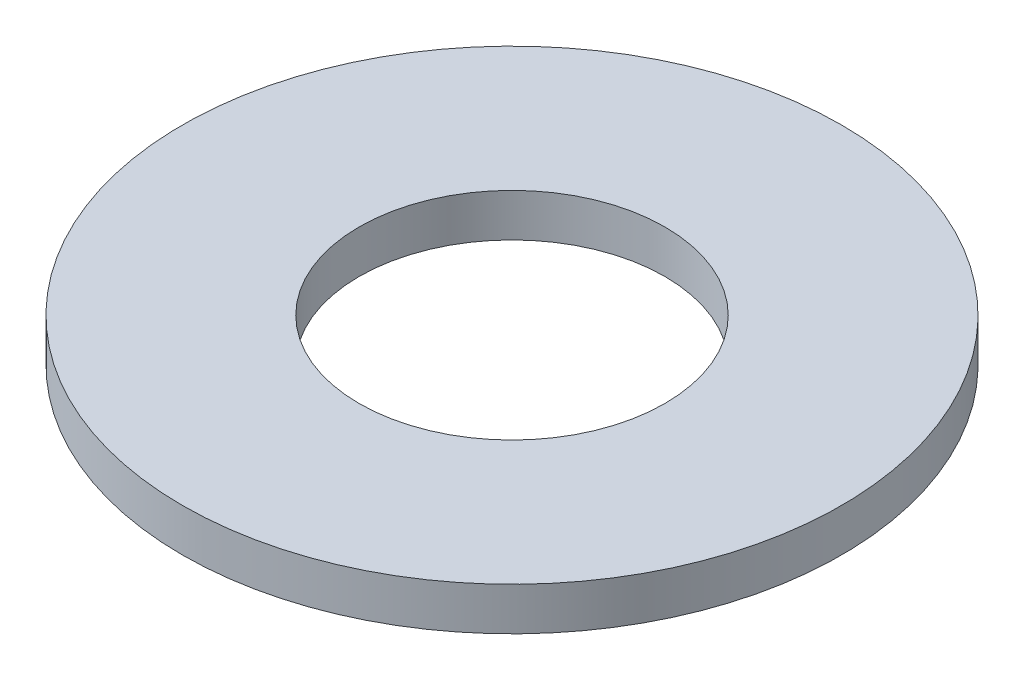
from build123d import *

# Parameters (mm, degrees)
SKETCH1_R           = 11.1125
BOSS_EXTRUDE1_DEPTH = 1.4478
SKETCH5_R           = 5.1562
CUT_EXTRUDE1_DEPTH  = 2.4478


with BuildPart() as part:
    # Sketch1 → Boss-Extrude1 (new body)
    with BuildSketch(Plane(origin=(0, 0, 0), x_dir=(1, 0, 0), z_dir=(0, 1, 0))):
        Circle(SKETCH1_R)
    extrude(amount=BOSS_EXTRUDE1_DEPTH)

    # Sketch5 → Cut-Extrude1 (cut, through all)
    with BuildSketch(Plane(origin=(0, 1.4478, 0), x_dir=(-1, 0, 0), z_dir=(0, 1, 0))):
        Circle(SKETCH5_R)
    extrude(amount=-CUT_EXTRUDE1_DEPTH, mode=Mode.SUBTRACT)


solid = part.part
